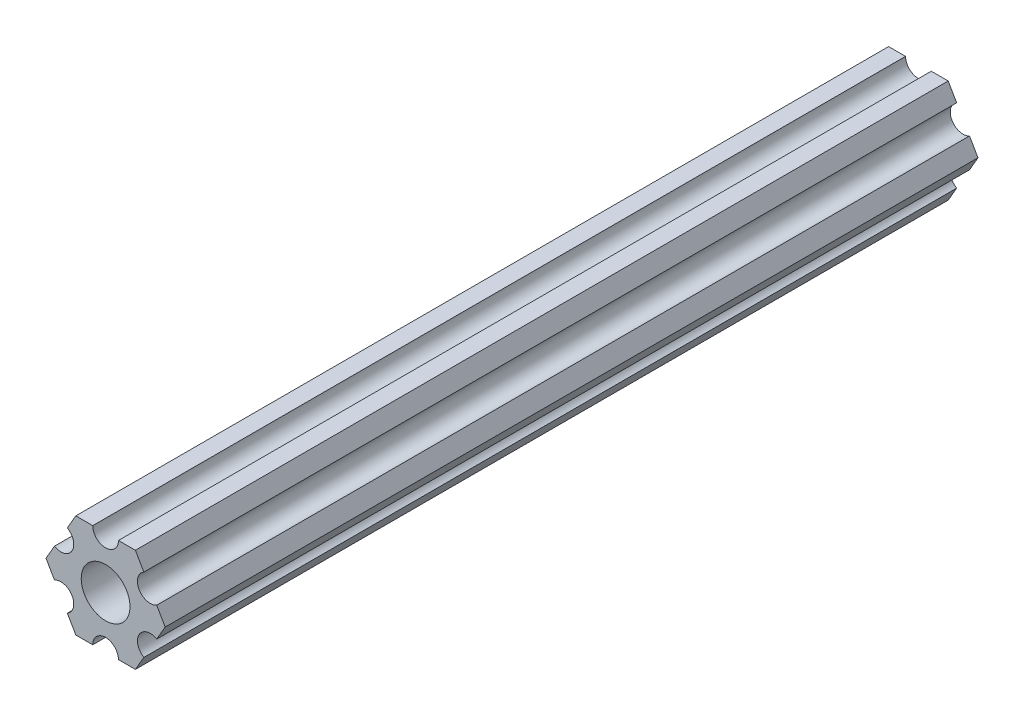
from build123d import *

# Parameters (mm, degrees)
Y_KSEKLIK_EKSTR_ZYON1_DEPTH = 100
IZIM6_R                     = 3
KES_EKSTR_ZYON2_DEPTH       = 1
KES_EKSTR_ZYON2_DEPTH_BACK  = 101


with BuildPart() as part:
    # Çizim4 → Yükseklik-Ekstrüzyon1 (new body)
    with BuildSketch(Plane.XY):
        with BuildLine():
            Line((-3.666174594, 6.349999778), (-1.581220903, 6.349999778))
            ThreePointArc((-1.581220903, 6.349999778), (-3.85e-07, 4.768779481), (1.581220134, 6.349999778))
            Line((1.581220134, 6.349999778), (3.666173825, 6.349999778))
            Line((3.666173825, 6.349999778), (4.708650587, 4.544377312))
            ThreePointArc((4.708650587, 4.544377312), (4.129884032, 2.384389991), (6.289871272, 1.805623132))
            Line((6.289871272, 1.805623132), (7.332348419, 0))
            Line((7.332348419, 0), (6.289871875, -1.805622592))
            ThreePointArc((6.289871875, -1.805622592), (4.12988432, -2.384389491), (4.708651522, -4.544376964))
            Line((4.708651522, -4.544376964), (3.666174594, -6.350000222))
            Line((3.666174594, -6.350000222), (1.581220903, -6.350000222))
            ThreePointArc((1.581220903, -6.350000222), (3.85e-07, -4.768779481), (-1.581220134, -6.350000222))
            Line((-1.581220134, -6.350000222), (-3.666173825, -6.350000222))
            Line((-3.666173825, -6.350000222), (-4.708650779, -4.544377423))
            ThreePointArc((-4.708650779, -4.544377423), (-4.129884032, -2.384389991), (-6.289871464, -1.805623243))
            Line((-6.289871464, -1.805623243), (-7.332348419, -4.44e-07))
            Line((-7.332348419, -4.44e-07), (-6.289871683, 1.805622481))
            ThreePointArc((-6.289871683, 1.805622481), (-4.12988432, 2.384389491), (-4.70865133, 4.544376853))
            Line((-4.70865133, 4.544376853), (-3.666174594, 6.349999778))
        make_face()
    extrude(amount=Y_KSEKLIK_EKSTR_ZYON1_DEPTH)

    # Çizim6 → Kes-Ekstrüzyon2 (cut, two sides)
    with BuildSketch(Plane(origin=(0, 0, 0), x_dir=(-1, 0, 0), z_dir=(0, 0, -1))) as kes_ekstr_zyon2_sk:
        Circle(IZIM6_R)
    extrude(amount=KES_EKSTR_ZYON2_DEPTH, mode=Mode.SUBTRACT)
    extrude(kes_ekstr_zyon2_sk.sketch, amount=-KES_EKSTR_ZYON2_DEPTH_BACK, mode=Mode.SUBTRACT)


solid = part.part
